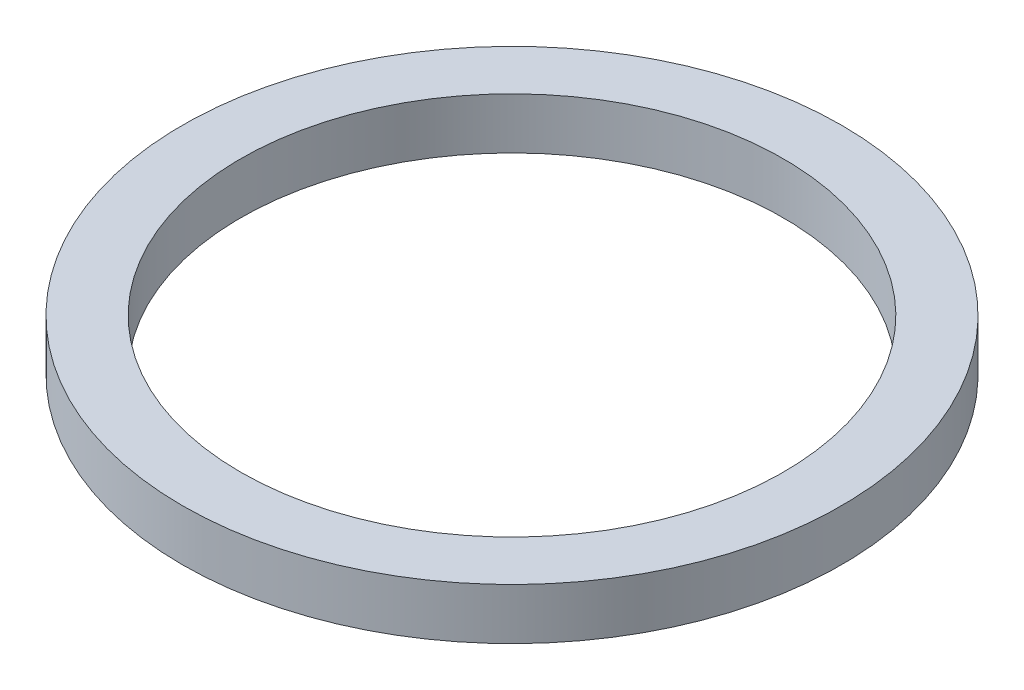
from build123d import *

# Parameters (mm, degrees)
SKETCH1_R           = 19.305
SKETCH1_R_2         = 15.9
BOSS_EXTRUDE1_DEPTH = 3


with BuildPart() as part:
    # Sketch1 → Boss-Extrude1 (new body)
    with BuildSketch(Plane(origin=(0, 0, 0), x_dir=(1, 0, 0), z_dir=(0, 1, 0))):
        Circle(SKETCH1_R)
        Circle(SKETCH1_R_2, mode=Mode.SUBTRACT)
    extrude(amount=BOSS_EXTRUDE1_DEPTH)


solid = part.part
